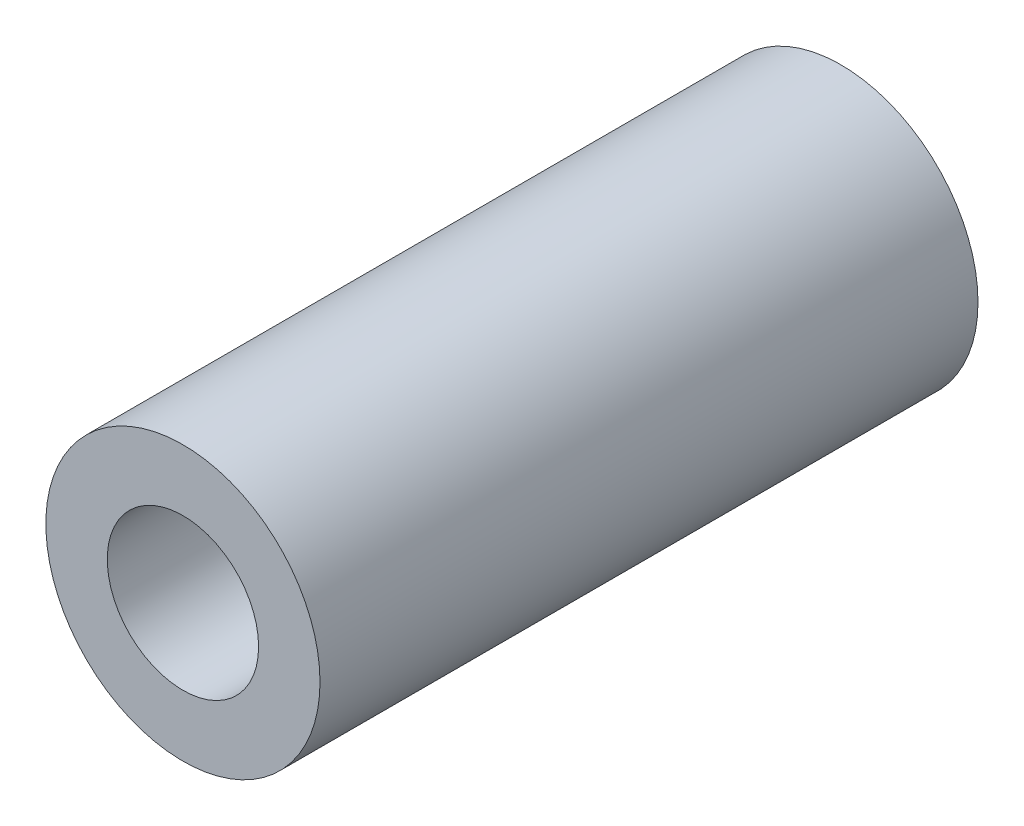
from build123d import *

# Parameters (mm, degrees)
SKETCH1_R           = 4.7625
SKETCH1_R_2         = 2.6289
BOSS_EXTRUDE1_DEPTH = 22.86


with BuildPart() as part:
    # Sketch1 → Boss-Extrude1 (new body)
    with BuildSketch(Plane.XY):
        Circle(SKETCH1_R)
        Circle(SKETCH1_R_2, mode=Mode.SUBTRACT)
    extrude(amount=BOSS_EXTRUDE1_DEPTH)


solid = part.part
